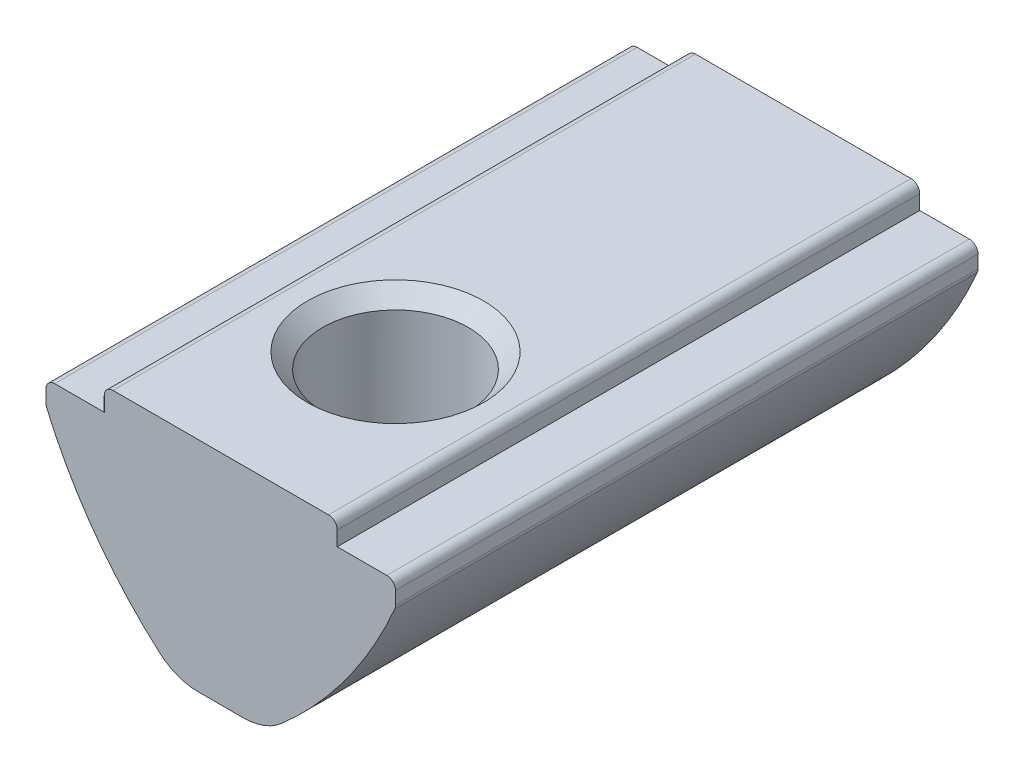
from build123d import *

# Parameters (mm, degrees)
EXTRUDE_1_DEPTH             = 10
FILLET_1_R                  = 0.3
FILLET_2_R                  = 2
HOLE_WIZARD_M61_D           = 5
HOLE_WIZARD_M61_CSINK_D     = 6.05
HOLE_WIZARD_M61_CSINK_ANGLE = 90


with BuildPart() as part:
    # Эскиз1 → Бобышка-Вытянуть1 (new body, symmetric)
    with BuildSketch(Plane.XY):
        with BuildLine():
            Line((-4, 0), (4, 0))
            Line((4, 0), (4, -0.8))
            Line((4, -0.8), (6, -0.8))
            Line((6, -0.8), (6, -1.6))
            ThreePointArc((6, -1.6), (4.120585945, -4.832650297), (1.5, -7.5))
            Line((1.5, -7.5), (-1.5, -7.5))
            ThreePointArc((-1.5, -7.5), (-4.120585945, -4.832650297), (-6, -1.6))
            Line((-6, -1.6), (-6, -0.8))
            Line((-6, -0.8), (-4, -0.8))
            Line((-4, -0.8), (-4, 0))
        make_face()
    extrude(amount=EXTRUDE_1_DEPTH, both=True)

    # Скругление1
    fillet_1_edges = [part.edges().sort_by_distance(p)[0] for p in [
        (6, -0.8, 0),
        (6, -1.6, 0),
        (-6, -1.6, 0),
        (-6, -0.8, 0),
        (-4, 0, 0),
        (4, 0, 0),
    ]]
    fillet(fillet_1_edges, radius=FILLET_1_R)

    # Скругление2
    fillet_2_edges = [part.edges().sort_by_distance(p)[0] for p in [
        (1.5, -7.5, 0),
        (-1.5, -7.5, 0),
    ]]
    fillet(fillet_2_edges, radius=FILLET_2_R)

    # Отверстие обработанное метчиком M61 (through all)
    with Locations(Plane(origin=(0, 0, 0), x_dir=(1, 0, 0), z_dir=(0, 1, 0))):
        with Locations((0, -4)):
            CounterSinkHole(HOLE_WIZARD_M61_D / 2, HOLE_WIZARD_M61_CSINK_D / 2, counter_sink_angle=HOLE_WIZARD_M61_CSINK_ANGLE)

    # Эскиз5 → Повернуть1 (revolve)
    with BuildSketch(Plane(origin=(0, 0, 0), x_dir=(0, 0, -1), z_dir=(1, 0, 0))):
        with BuildLine():
            Line((6, -4.3), (6, -8.3))
            ThreePointArc((6, -8.3), (4, -6.3), (6, -4.3))
        make_face()
    revolve(axis=Axis((0, -4.3, -6), (0, -1, 0)))


solid = part.part
